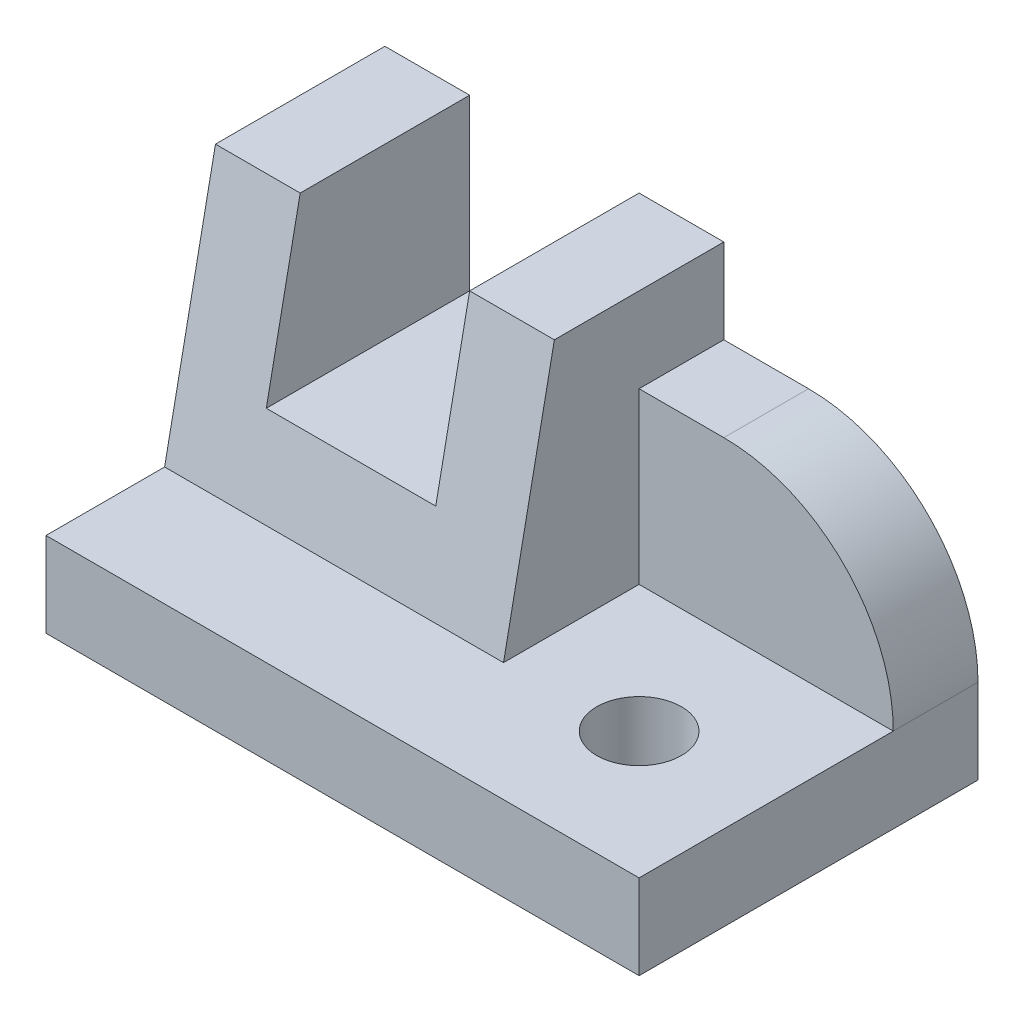
from build123d import *

# Parameters (mm, degrees)
BOSS_EXTRUDE1_DEPTH            = 40
SKETCH2_W                      = 40
SKETCH2_H                      = 30
BOSS_EXTRUDE2_DEPTH            = 20
BOSS_EXTRUDE3_DEPTH            = 30
CUT_EXTRUDE1_DEPTH             = 30
SKETCH5_W                      = 70
SKETCH5_H                      = 40
BOSS_EXTRUDE4_DEPTH            = 10
SKETCH6_W                      = 20
SKETCH6_H                      = 20
CUT_EXTRUDE2_DEPTH             = 41
F_10_0_10_DIAMETER_HOLE1_D     = 10
F_10_0_10_DIAMETER_HOLE1_DEPTH = 40
FILLET1_R                      = 20


with BuildPart() as part:
    # Sketch1 → Boss-Extrude1 (new body)
    with BuildSketch(Plane(origin=(0, 0, 0), x_dir=(0, -1, 0), z_dir=(-1, 0, 0))):
        Polygon((-10, -14), (-40, -20), (-10, -20), align=None)
    extrude(amount=-BOSS_EXTRUDE1_DEPTH)

    # Sketch2 → Boss-Extrude2 (add)
    with BuildSketch(Plane(origin=(0, 0, -20), x_dir=(-1, 0, 0), z_dir=(0, 0, -1))):
        with Locations((-20, 25)):
            Rectangle(SKETCH2_W, SKETCH2_H)
    extrude(amount=BOSS_EXTRUDE2_DEPTH)

    # Sketch3 → Boss-Extrude3 (add)
    with BuildSketch(Plane(origin=(40, 0, 0), x_dir=(0, 0, -1), z_dir=(1, 0, 0))):
        Polygon((40, 10), (0, 10), (20, 40), (40, 40), align=None)
    extrude(amount=BOSS_EXTRUDE3_DEPTH)

    # Sketch4 → Cut-Extrude1 (cut)
    with BuildSketch(Plane(origin=(70, 0, 0), x_dir=(0, 0, -1), z_dir=(1, 0, 0))):
        Polygon((20, 40), (0, 10), (30, 10), (30, 30), (40, 30), (40, 40), align=None)
    extrude(amount=-CUT_EXTRUDE1_DEPTH, mode=Mode.SUBTRACT)

    # Sketch5 → Boss-Extrude4 (add)
    with BuildSketch(Plane.XZ.offset(-10)):
        with Locations((35, -20)):
            Rectangle(SKETCH5_W, SKETCH5_H)
    extrude(amount=BOSS_EXTRUDE4_DEPTH)

    # Sketch6 → Cut-Extrude2 (cut, through all)
    with BuildSketch(Plane(origin=(0, 0, -40), x_dir=(-1, 0, 0), z_dir=(0, 0, -1))):
        with Locations((-20, 30)):
            Rectangle(SKETCH6_W, SKETCH6_H)
    extrude(amount=-CUT_EXTRUDE2_DEPTH, mode=Mode.SUBTRACT)

    # Ø10.0 (10) Diameter Hole1
    with Locations(Plane(origin=(0, 0, 0), x_dir=(-1, 0, 0), z_dir=(0, -1, 0))):
        with Locations((-55, 15)):
            Hole(F_10_0_10_DIAMETER_HOLE1_D / 2, depth=F_10_0_10_DIAMETER_HOLE1_DEPTH)

    # Fillet1
    fillet1_edges = [part.edges().sort_by_distance(p)[0] for p in [
        (70, 30, -35),
    ]]
    fillet(fillet1_edges, radius=FILLET1_R)


solid = part.part
